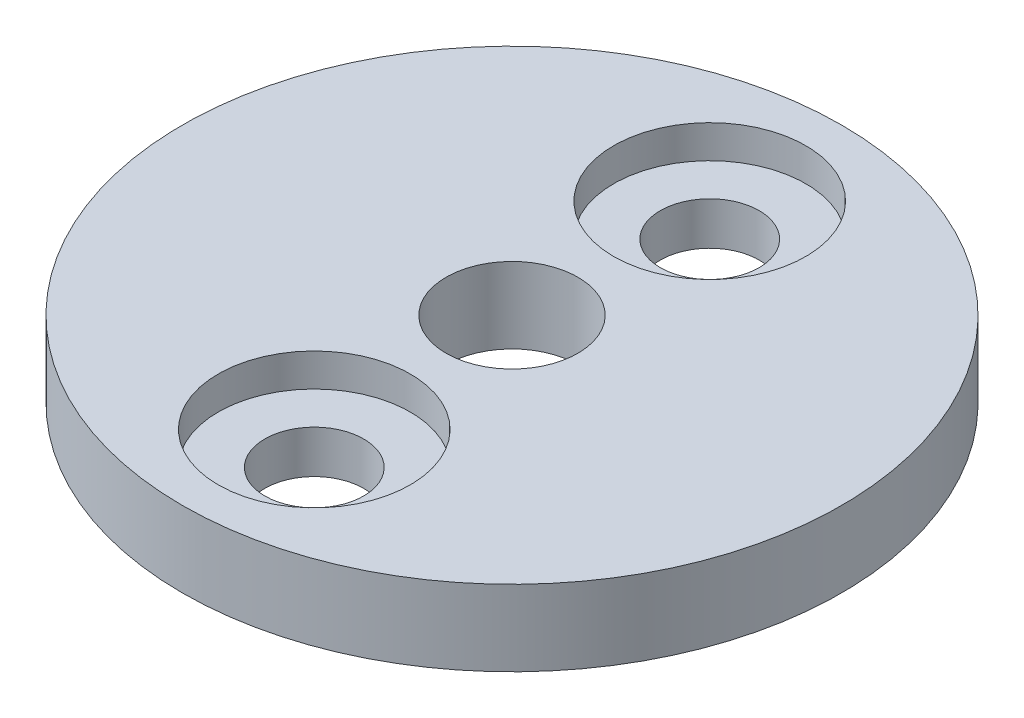
from build123d import *

# Parameters (mm, degrees)
SKETCH1_R           = 10
SKETCH1_R_2         = 2
SKETCH1_R_3         = 1.5
BOSS_EXTRUDE1_DEPTH = 2.3
SKETCH2_R           = 2.915
CUT_EXTRUDE1_DEPTH  = 1


with BuildPart() as part:
    # Sketch1 → Boss-Extrude1 (new body)
    with BuildSketch(Plane(origin=(0, 16.875, 0), x_dir=(1, 0, 0), z_dir=(0, 1, 0))):
        Circle(SKETCH1_R)
        Circle(SKETCH1_R_2, mode=Mode.SUBTRACT)
        with Locations((0, 6)):
            Circle(SKETCH1_R_3, mode=Mode.SUBTRACT)
        with Locations((0, -6)):
            Circle(SKETCH1_R_3, mode=Mode.SUBTRACT)
    extrude(amount=BOSS_EXTRUDE1_DEPTH)

    # Sketch2 → Cut-Extrude1 (cut)
    with BuildSketch(Plane(origin=(0, 19.175, 0), x_dir=(1, 0, 0), z_dir=(0, 1, 0))):
        with Locations((0, 6)):
            Circle(SKETCH2_R)
        with Locations((0, -6)):
            Circle(SKETCH2_R)
    extrude(amount=-CUT_EXTRUDE1_DEPTH, mode=Mode.SUBTRACT)


solid = part.part
